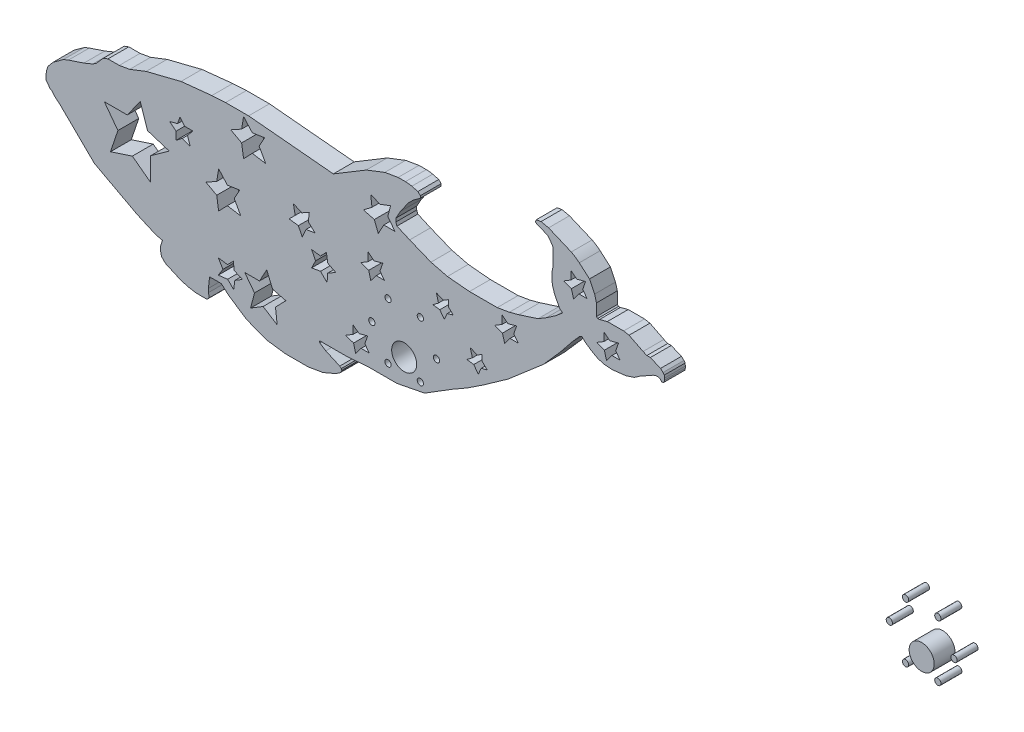
from build123d import *

# Parameters (mm, degrees)
SKETCH_1_R            = 6
BOSS_EXTRUDE1_DEPTH   = 10
SKETCH_1_R_2          = 1.5
BOSS_EXTRUDE1_2_DEPTH = 10
BOSS_EXTRUDE1_3_DEPTH = 10
BOSS_EXTRUDE1_4_DEPTH = 10
BOSS_EXTRUDE1_5_DEPTH = 10
BOSS_EXTRUDE1_6_DEPTH = 10
BOSS_EXTRUDE1_7_DEPTH = 10
BOSS_EXTRUDE1_8_DEPTH = 10


with BuildPart() as part:
    # 草图1 → Boss-Extrude1 (new body)
    with BuildSketch(Plane.XY):
        with Locations((363.927057015, 7.349323606)):
            Circle(SKETCH_1_R)
    extrude(amount=BOSS_EXTRUDE1_DEPTH)


with BuildPart() as body_2:
    # 草图1 → Boss-Extrude1 2 (new body)
    with BuildSketch(Plane.XY):
        with Locations((348.427057015, 14.349323606)):
            Circle(SKETCH_1_R_2)
    extrude(amount=BOSS_EXTRUDE1_2_DEPTH)


with BuildPart() as body_3:
    # 草图1 → Boss-Extrude1 3 (new body)
    with BuildSketch(Plane.XY):
        with Locations((356.177057015, 0.925929848)):
            Circle(SKETCH_1_R_2)
    extrude(amount=BOSS_EXTRUDE1_3_DEPTH)


with BuildPart() as body_4:
    # 草图1 → Boss-Extrude1 4 (new body)
    with BuildSketch(Plane.XY):
        with Locations((371.677057015, 0.925929848)):
            Circle(SKETCH_1_R_2)
    extrude(amount=BOSS_EXTRUDE1_4_DEPTH)


with BuildPart() as body_5:
    # 草图1 → Boss-Extrude1 5 (new body)
    with BuildSketch(Plane.XY):
        with Locations((379.427057015, 14.349323606)):
            Circle(SKETCH_1_R_2)
    extrude(amount=BOSS_EXTRUDE1_5_DEPTH)


with BuildPart() as body_6:
    # 草图1 → Boss-Extrude1 6 (new body)
    with BuildSketch(Plane.XY):
        with Locations((371.677057015, 27.772717365)):
            Circle(SKETCH_1_R_2)
    extrude(amount=BOSS_EXTRUDE1_6_DEPTH)


with BuildPart() as body_7:
    # 草图1 → Boss-Extrude1 7 (new body)
    with BuildSketch(Plane.XY):
        with Locations((356.177057015, 27.772717365)):
            Circle(SKETCH_1_R_2)
    extrude(amount=BOSS_EXTRUDE1_7_DEPTH)


with BuildPart() as body_8:
    # 草图1 → Boss-Extrude1 8 (new body)
    with BuildSketch(Plane.XY):
        with BuildLine():
            Line((-33.410657642, 54.831138699), (-37.659766665, 53.081505572))
            Line((-37.659766665, 53.081505572), (-42.058844242, 51.631809552))
            Line((-42.058844242, 51.631809552), (-45.046732576, 50.647164533))
            Line((-45.046732576, 50.647164533), (-47.432835444, 49.664651588))
            Line((-47.432835444, 49.664651588), (-49.757230002, 47.982574744))
            Line((-49.757230002, 47.982574744), (-51.192577521, 46.943867776))
            Line((-51.192577521, 46.943867776), (-52.408019154, 46.064298419))
            Line((-52.408019154, 46.064298419), (-53.663094015, 44.574110716))
            Line((-53.663094015, 44.574110716), (-54.867452772, 43.144139751))
            Line((-54.867452772, 43.144139751), (-55.483289473, 41.278081102))
            Line((-55.483289473, 41.278081102), (-55.827650776, 39.292359051))
            Line((-55.827650776, 39.292359051), (-55.827650776, 37.258314176))
            Line((-55.827650776, 37.258314176), (-55.827650776, 37.0689284))
            Line((-55.827650776, 37.0689284), (-55.046462085, 35.989435064))
            Line((-55.046462085, 35.989435064), (-53.663094015, 34.077814186))
            Line((-53.663094015, 34.077814186), (-53.035556585, 34.077814186))
            Line((-53.035556585, 34.077814186), (-51.800298337, 32.370860334))
            Line((-51.800298337, 32.370860334), (-49.757230002, 30.650135017))
            Line((-49.757230002, 30.650135017), (-48.966755164, 29.98437654))
            Line((-48.966755164, 29.98437654), (-40.564351466, 21.73465033))
            Line((-40.564351466, 21.73465033), (-32.603210869, 13.918169166))
            Line((-32.603210869, 13.918169166), (-27.285360116, 11.083792685))
            Line((-27.285360116, 11.083792685), (-23.268229618, 8.942690812))
            Line((-23.268229618, 8.942690812), (-20.298434904, 7.359811435))
            Line((-20.298434904, 7.359811435), (-16.864689953, 5.529649894))
            Line((-16.864689953, 5.529649894), (-12.129991144, 3.006089235))
            Line((-12.129991144, 3.006089235), (-7.801946615, 1.088980385))
            Line((-7.801946615, 1.088980385), (-4.073964468, -0.562330621))
            Line((-4.073964468, -0.562330621), (-0.664290627, -1.635315793))
            Line((-0.664290627, -1.635315793), (0, -1.635315793))
            Line((0, -1.635315793), (-0.902565897, -4.503440543))
            Line((-0.902565897, -4.503440543), (-0.902565897, -6.54100518))
            Line((-0.902565897, -6.54100518), (-0.451282949, -8.649024522))
            Line((-0.451282949, -8.649024522), (1.504969794, -10.569730798))
            Line((1.504969794, -10.569730798), (4.827727379, -12.041547442))
            Line((4.827727379, -12.041547442), (8.423412197, -13.6342573))
            Line((8.423412197, -13.6342573), (12.004196913, -14.761089098))
            Line((12.004196913, -14.761089098), (16.190320712, -15.472539593))
            Line((16.190320712, -15.472539593), (19.755179374, -15.472539593))
            Line((19.755179374, -15.472539593), (21.366644527, -15.472539593))
            Line((21.366644527, -15.472539593), (22.457405554, -14.284936039))
            Line((22.457405554, -14.284936039), (22.043569554, -12.351837755))
            Line((22.043569554, -12.351837755), (22.043569554, -10.569730798))
            Line((22.043569554, -10.569730798), (22.457405554, -6.541005179))
            Line((22.457405554, -6.541005179), (22.457405554, -5.52222286))
            Line((22.457405554, -5.52222286), (26.7724246, -5.52222286))
            Line((26.7724246, -5.52222286), (28.170157324, -5.52222286))
            Line((28.170157324, -5.52222286), (31.728241973, -8.649024521))
            Line((31.728241973, -8.649024521), (35.573852451, -11.219701923))
            Line((35.573852451, -11.219701923), (39.801144085, -14.045521941))
            Line((39.801144085, -14.045521941), (44.121313697, -15.959142594))
            Line((44.121313697, -15.959142594), (49.998123581, -18.084264689))
            Line((49.998123581, -18.084264689), (54.983287953, -18.758002092))
            Line((54.983287953, -18.758002092), (58.943275959, -19.293188464))
            Line((58.943275959, -19.293188464), (64.900307309, -19.293188464))
            Line((64.900307309, -19.293188464), (69.873778171, -19.293188464))
            Line((69.873778171, -19.293188464), (76.958655014, -18.084264689))
            Line((76.958655014, -18.084264689), (81.9058535, -15.959142594))
            Line((81.9058535, -15.959142594), (84.797256924, -14.430024053))
            Line((84.797256924, -14.430024053), (85.704719999, -13.397393656))
            Line((85.704719999, -13.397393656), (85.981273873, -12.632611931))
            Line((85.981273873, -12.632611931), (85.727375792, -12.041547442))
            Line((85.727375792, -12.041547442), (84.977389377, -11.382468472))
            Line((84.977389377, -11.382468472), (83.142561458, -10.569730798))
            Line((83.142561458, -10.569730798), (78.292603949, -8.42144041))
            Line((78.292603949, -8.42144041), (75.982674159, -6.877320343))
            Line((75.982674159, -6.877320343), (75.479562753, -6.541005178))
            Line((75.479562753, -6.541005178), (75.260748325, -6.031614019))
            Line((75.260748325, -6.031614019), (75.260748325, -5.686188531))
            Line((75.260748325, -5.686188531), (77.469541414, -5.686188531))
            Line((77.469541414, -5.686188531), (88.664530327, -5.686188531))
            Line((88.664530327, -5.686188531), (98.376741224, -4.87540565))
            Line((98.376741224, -4.87540565), (112.413024787, -4.87540565))
            Line((112.413024787, -4.87540565), (125.625106416, -2.294605889))
            Line((125.625106416, -2.294605889), (128.8781524, -0.275673635))
            Line((128.8781524, -0.275673635), (139.099216662, 6.067807648))
            Line((139.099216662, 6.067807648), (145.990972976, 10.013241751))
            Line((145.990972976, 10.013241751), (154.130629519, 15.402683661))
            Line((154.130629519, 15.402683661), (165.684208561, 23.570885411))
            Line((165.684208561, 23.570885411), (174.754787872, 31.381662041))
            Line((174.754787872, 31.381662041), (182.735935611, 38.25431704))
            Line((182.735935611, 38.25431704), (190.688049902, 47.303274684))
            Line((190.688049902, 47.303274684), (196.452402059, 54.437018499))
            Line((196.452402059, 54.437018499), (199.796268782, 58.242108218))
            Line((199.796268782, 58.242108218), (200.627787601, 58.820069172))
            Line((200.627787601, 58.820069172), (201.321946532, 58.820069172))
            Line((201.321946532, 58.820069172), (201.723667884, 58.242108218))
            Line((201.723667884, 58.242108218), (202.972964596, 57.144241411))
            Line((202.972964596, 57.144241411), (205.387734555, 55.473231471))
            Line((205.387734555, 55.473231471), (208.635406695, 53.613877193))
            Line((208.635406695, 53.613877193), (211.833496055, 52.74617853))
            Line((211.833496055, 52.74617853), (215.477830441, 52.423890455))
            Line((215.477830441, 52.423890455), (222.1425495, 53.180027862))
            Line((222.1425495, 53.180027862), (226.255143667, 54.543554334))
            Line((226.255143667, 54.543554334), (228.794730701, 56.308736443))
            Line((228.794730701, 56.308736443), (233.221579853, 58.820069175))
            Line((233.221579853, 58.820069175), (235.179708155, 59.930907049))
            Line((235.179708155, 59.930907049), (236.683829747, 60.429597054))
            Line((236.683829747, 60.429597054), (237.641319003, 60.429597054))
            Line((237.641319003, 60.429597054), (238.746184269, 59.930907049))
            Line((238.746184269, 59.930907049), (239.132237418, 59.375488112))
            Line((239.132237418, 59.375488112), (239.477850683, 59.219492729))
            Line((239.477850683, 59.219492729), (239.835288458, 59.219492729))
            Line((239.835288458, 59.219492729), (240.459264428, 59.653197581))
            Line((240.459264428, 59.653197581), (240.628227874, 60.59243312))
            Line((240.628227874, 60.59243312), (240.628227874, 61.432425915))
            Line((240.628227874, 61.432425915), (240.543746151, 62.654616479))
            Line((240.543746151, 62.654616479), (239.975238775, 63.472534331))
            Line((239.975238775, 63.472534331), (238.746184269, 64.540281919))
            Line((238.746184269, 64.540281919), (236.683829747, 65.413275179))
            Line((236.683829747, 65.413275179), (235.179708154, 66.049968821))
            Line((235.179708154, 66.049968821), (233.865705666, 66.606185175))
            Line((233.865705666, 66.606185175), (232.191369003, 66.606185175))
            Line((232.191369003, 66.606185175), (230.377363594, 67.374052425))
            Line((230.377363594, 67.374052425), (225.914432259, 69.624833485))
            Line((225.914432259, 69.624833485), (223.657179415, 70.763229209))
            Line((223.657179415, 70.763229209), (221.048417376, 71.232531534))
            Line((221.048417376, 71.232531534), (219.22180434, 71.232531534))
            Line((219.22180434, 71.232531534), (213.249153536, 71.232531534))
            Line((213.249153536, 71.232531534), (209.478003196, 70.194031347))
            Line((209.478003196, 70.194031347), (208.635406694, 70.194031347))
            Line((208.635406694, 70.194031347), (208.037712375, 70.713281441))
            Line((208.037712375, 70.713281441), (208.037712375, 73.125784561))
            Line((208.037712375, 73.125784561), (208.037712375, 76.379638491))
            Line((208.037712375, 76.379638491), (207.154609882, 79.586486507))
            Line((207.154609882, 79.586486507), (204.698115314, 84.647531489))
            Line((204.698115314, 84.647531489), (199.79626878, 88.906036536))
            ThreePointArc((199.79626878, 88.906036536), (197.949869571, 90.313577679), (195.939029773, 91.474131607))
            Line((195.939029773, 91.474131607), (190.688049899, 93.696867798))
            Line((190.688049899, 93.696867798), (186.838760194, 95.326269498))
            Line((186.838760194, 95.326269498), (185.085103058, 96.068591365))
            Line((185.085103058, 96.068591365), (181.47053747, 96.848135461))
            Line((181.47053747, 96.848135461), (179.174900606, 96.458363413))
            Line((179.174900606, 96.458363413), (178.65298574, 95.225394576))
            Line((178.65298574, 95.225394576), (179.74105602, 94.76481517))
            Line((179.74105602, 94.76481517), (182.263969094, 93.69686779))
            Line((182.263969094, 93.69686779), (184.681852838, 92.673379255))
            Line((184.681852838, 92.673379255), (185.961931631, 91.16435823))
            Line((185.961931631, 91.16435823), (187.153202533, 89.199508725))
            Line((187.153202533, 89.199508725), (187.153202533, 86.755427634))
            Line((187.153202533, 86.755427634), (187.153202533, 83.017421259))
            Line((187.153202533, 83.017421259), (187.153202533, 80.669186485))
            Line((187.153202533, 80.669186485), (186.642357747, 78.300517419))
            Line((186.642357747, 78.300517419), (186.642357747, 76.379638483))
            Line((186.642357747, 76.379638483), (186.642357747, 75.192050599))
            Line((186.642357747, 75.192050599), (187.04593778, 72.815088974))
            Line((187.04593778, 72.815088974), (187.88217113, 70.194031338))
            Line((187.88217113, 70.194031338), (189.279258052, 67.374052415))
            Line((189.279258052, 67.374052415), (190.250675329, 65.413275169))
            Line((190.250675329, 65.413275169), (191.801060267, 64.071032857))
            Line((191.801060267, 64.071032857), (188.580714591, 61.339264287))
            Line((188.580714591, 61.339264287), (184.042253481, 58.242108212))
            Line((184.042253481, 58.242108212), (179.994785862, 55.788164341))
            Line((179.994785862, 55.788164341), (176.13214836, 54.555812081))
            Line((176.13214836, 54.555812081), (170.844169808, 52.868712964))
            Line((170.844169808, 52.868712964), (166.275043698, 51.631809551))
            Line((166.275043698, 51.631809551), (162.44284044, 50.981146663))
            Line((162.44284044, 50.981146663), (160.475788938, 50.647164532))
            Line((160.475788938, 50.647164532), (147.151416723, 50.647164532))
            Line((147.151416723, 50.647164532), (136.601823128, 51.631809551))
            Line((136.601823128, 51.631809551), (128.696987069, 53.613877186))
            Line((128.696987069, 53.613877186), (118.488202163, 57.754122119))
            Line((118.488202163, 57.754122119), (112.413024787, 60.429597045))
            Line((112.413024787, 60.429597045), (111.860373303, 61.852092411))
            Line((111.860373303, 61.852092411), (111.860373303, 63.472534321))
            Line((111.860373303, 63.472534321), (114.075704911, 67.374052416))
            Line((114.075704911, 67.374052416), (117.867527767, 72.815088975))
            Line((117.867527767, 72.815088975), (120.310243781, 75.192050599))
            Line((120.310243781, 75.192050599), (122.645669863, 76.896286601))
            Line((122.645669863, 76.896286601), (123.592594616, 77.587288241))
            Line((123.592594616, 77.587288241), (123.592594616, 78.647856162))
            Line((123.592594616, 78.647856162), (122.447292067, 79.824841456))
            Line((122.447292067, 79.824841456), (119.526989001, 80.557081587))
            ThreePointArc((119.526989001, 80.557081587), (118.01680241, 80.838536565), (116.483508745, 80.932828558))
            Line((116.483508745, 80.932828558), (112.968039107, 80.932828558))
            Line((112.968039107, 80.932828558), (106.585749275, 79.824841456))
            Line((106.585749275, 79.824841456), (97.71798106, 76.379638483))
            Line((97.71798106, 76.379638483), (91.800480293, 72.815088975))
            Line((91.800480293, 72.815088975), (86.927592009, 69.879787026))
            Line((86.927592009, 69.879787026), (83.142561457, 67.599782456))
            Line((83.142561457, 67.599782456), (81.905853498, 66.854821548))
            Line((81.905853498, 66.854821548), (61.71015328, 68.739784741))
            Line((61.71015328, 68.739784741), (49.496045079, 69.879787026))
            Line((49.496045079, 69.879787026), (41.287431822, 70.645936934))
            Line((41.287431822, 70.645936934), (35.048711502, 70.645936934))
            Line((35.048711502, 70.645936934), (30.243094938, 70.645936934))
            Line((30.243094938, 70.645936934), (23.66698806, 70.26286198))
            Line((23.66698806, 70.26286198), (8.908746791, 68.739784742))
            Line((8.908746791, 68.739784742), (-7.801946615, 64.540281911))
            Line((-7.801946615, 64.540281911), (-15.704954792, 61.469896374))
            Line((-15.704954792, 61.469896374), (-20.702931438, 60.592433112))
            Line((-20.702931438, 60.592433112), (-24.373963731, 60.592433112))
            Line((-24.373963731, 60.592433112), (-26.124763748, 60.592433112))
            Line((-26.124763748, 60.592433112), (-28.37351312, 59.718774956))
            Line((-28.37351312, 59.718774956), (-30.134660561, 57.75412212))
            Line((-30.134660561, 57.75412212), (-31.734724425, 55.969166509))
            Line((-31.734724425, 55.969166509), (-33.410657642, 54.831138699))
        make_face()
        with Locations((115.864266365, 7.770365569)):
            Circle(SKETCH_1_R, mode=Mode.SUBTRACT)
        with Locations((100.364266365, 14.770365569)):
            Circle(SKETCH_1_R_2, mode=Mode.SUBTRACT)
        with Locations((108.114266365, 1.34697181)):
            Circle(SKETCH_1_R_2, mode=Mode.SUBTRACT)
        with Locations((123.614266365, 1.34697181)):
            Circle(SKETCH_1_R_2, mode=Mode.SUBTRACT)
        with Locations((131.364266365, 14.770365569)):
            Circle(SKETCH_1_R_2, mode=Mode.SUBTRACT)
        with Locations((123.614266365, 28.193759327)):
            Circle(SKETCH_1_R_2, mode=Mode.SUBTRACT)
        with Locations((108.114266365, 28.193759327)):
            Circle(SKETCH_1_R_2, mode=Mode.SUBTRACT)
        Polygon((66.796314816, 43.144139751), (70.414594245, 45.16845906), (69.873778169, 41.048221791), (73.133532545, 37.973730021), (68.825061085, 37.262623082), (67.026378826, 33.226045452), (65.123122016, 36.994279168), (60.689151729, 37.576275362), (63.617248497, 40.483519221), (62.738822277, 44.95930996), align=None, mode=Mode.SUBTRACT)
        Polygon((-10.655305835, 50.647164533), (-16.864689953, 41.939459982), (-27.868197128, 41.939459982), (-21.368723652, 33.226045452), (-24.933875724, 22.635729607), (-14.438350327, 26.066173705), (-5.624027591, 19.484306498), (-5.624027591, 30.650135018), (3.209962207, 36.994279168), (-7.19567779, 40.298595925), align=None, mode=Mode.SUBTRACT)
        Polygon((78.585199273, 32.680529142), (75.767815315, 29.69337537), (71.503655357, 30.253082519), (73.398067408, 26.502360427), (71.503655357, 22.635729607), (75.767815315, 23.363342022), (78.9066154, 20.202028135), (79.229940862, 24.350951656), (83.142561457, 26.539946059), (79.229940862, 28.45689028), align=None, mode=Mode.SUBTRACT)
        Polygon((38.883825102, 69.188305201), (37.946019259, 63.472534323), (32.752017671, 60.592433112), (37.946019259, 57.75412212), (38.88059479, 51.631809552), (43.067881937, 55.969166509), (49.496045079, 54.914476061), (46.347588017, 60.592433112), (48.981982476, 65.413275171), (43.067881937, 64.51048336), align=None, mode=Mode.SUBTRACT)
        Polygon((8.423412197, 53.800488031), (10.574087094, 50.981146665), (14.502977168, 50.981146665), (12.004196913, 47.750936847), (13.25358704, 44.044880739), (9.498749646, 45.392537506), (6.551302402, 43.144139751), (6.551302402, 46.943867775), (3.420122637, 49.366041756), (7.231245865, 50.390098015), align=None, mode=Mode.SUBTRACT)
        Polygon((91.354137012, 8.942690812), (94.226758659, 6.720528582), (98.376741224, 7.835637007), (97.001522669, 3.901595671), (99.147066718, 1.088980385), (95.238268604, 1.088980385), (92.620841549, -2.294605889), (91.711665305, 1.088980385), (91.602833181, 1.494009532), (87.830190936, 2.812807982), (91.354137012, 4.951997279), align=None, mode=Mode.SUBTRACT)
        Polygon((99.828125008, 67.374052417), (104.226515176, 65.413275171), (109.341728777, 67.374052417), (108.018608353, 62.254177662), (111.451380491, 57.75412212), (106.115795566, 57.75412212), (103.436495764, 52.868712965), (101.563807768, 57.75412212), (96.301749941, 59.113986671), (100.418257913, 62.254177662), align=None, mode=Mode.SUBTRACT)
        Polygon((49.998123581, 11.083792685), (46.502750257, 4.710363023), (39.430278737, 4.710363023), (44.121313697, -1.439161915), (42.258081308, -8.649024522), (48.250436919, -5.011402745), (54.983287952, -9.265170941), (54.17983865, -2.294605889), (59.130984007, 2.812807982), (52.768157594, 4.457142265), align=None, mode=Mode.SUBTRACT)
        Polygon((33.947620013, 6.67050939), (31.223749959, 3.860668294), (26.7724246, 4.459550039), (28.99808728, 0.793153952), (26.7724246, -2.729617996), (31.223749959, -2.216544203), (34.140542342, -5.044093218), (34.688909102, -0.968232022), (38.328751179, 1.241311213), (34.414725722, 2.986161434), align=None, mode=Mode.SUBTRACT)
        Polygon((195.77878161, 83.738942811), (198.651403257, 81.516780581), (202.801385821, 82.631889006), (201.426167266, 78.69784767), (203.571711316, 75.885232384), (199.662913202, 75.885232384), (197.045486146, 72.501646109), (196.136309902, 75.885232384), (196.027477779, 76.29026153), (192.254835534, 77.60905998), (195.77878161, 79.748249277), align=None, mode=Mode.SUBTRACT)
        Polygon((162.741872701, 48.771305459), (165.614494348, 46.549143229), (169.764476913, 47.664251654), (168.389258358, 43.730210318), (170.534802407, 40.917595032), (166.626004293, 40.917595032), (164.008577237, 37.534008758), (163.099400993, 40.917595032), (162.99056887, 41.322624178), (159.217926625, 42.641422629), (162.741872701, 44.780611925), align=None, mode=Mode.SUBTRACT)
        Polygon((98.598783325, 42.764594748), (101.471404973, 40.542432518), (105.621387537, 41.657540943), (104.246168982, 37.723499607), (106.391713032, 34.910884321), (102.482914918, 34.910884321), (99.865487862, 31.527298047), (98.956311618, 34.910884321), (98.847479495, 35.315913468), (95.074837249, 36.634711918), (98.598783325, 38.773901215), align=None, mode=Mode.SUBTRACT)
        Polygon((136.998776482, 42.208824033), (134.591939449, 40.747768754), (131.285197109, 42.221895626), (132.301241235, 38.440590318), (129.658964672, 36.424985559), (132.938568279, 35.983747372), (135.141623396, 33.095740249), (136.52743123, 36.204366465), (139.390609071, 36.973707946), (136.998776482, 39.292359051), align=None, mode=Mode.SUBTRACT)
        Polygon((153.260881292, 27.596497971), (150.85404426, 26.135442692), (147.54730192, 27.609569564), (148.563346046, 23.828264256), (145.921069483, 21.812659497), (149.20067309, 21.37142131), (151.403728207, 18.483414187), (152.789536041, 21.592040403), (155.652713881, 22.361381884), (153.260881292, 24.68003299), align=None, mode=Mode.SUBTRACT)
        Polygon((26.932875779, 41.48787198), (25.995069937, 35.772101103), (20.801068348, 32.891999891), (25.995069937, 30.0536889), (26.929645468, 23.931376332), (31.116932615, 28.268733289), (37.545095757, 27.214042841), (34.396638695, 32.891999891), (37.031033154, 37.712841951), (31.116932615, 36.810050139), align=None, mode=Mode.SUBTRACT)
        Polygon((211.593698848, 66.095818645), (214.466320496, 63.873656415), (218.61630306, 64.98876484), (217.241084505, 61.054723505), (219.386628555, 58.242108218), (215.477830441, 58.242108218), (212.860403385, 54.858521944), (211.951227141, 58.242108218), (211.842395018, 58.647137365), (208.069752772, 59.965935815), (211.593698848, 62.105125112), align=None, mode=Mode.SUBTRACT)
    extrude(amount=BOSS_EXTRUDE1_8_DEPTH)


solid = Compound([part.part, body_2.part, body_3.part, body_4.part, body_5.part, body_6.part, body_7.part, body_8.part])
